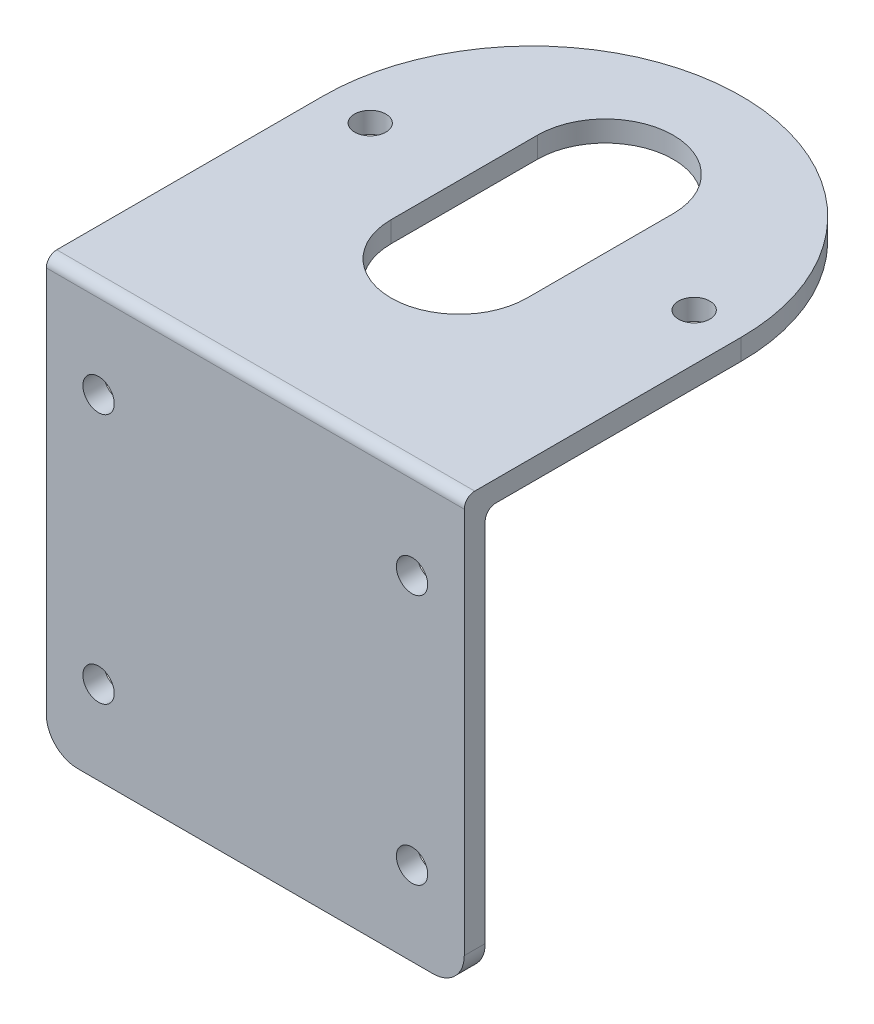
from build123d import *

# Parameters (mm, degrees)
SKETCH_1_W      = 40
SKETCH_1_H      = 39
SKETCH_1_R      = 1.5
SKETCH_1_H_2    = 2
EXTRUDE_2_DEPTH = 2
EXTRUDE_3_DEPTH = 2
FILLET_1_R      = 1
FILLET_2_R      = 3


with BuildPart() as part:
    # 草图1 → 凸台-拉伸2 (new body)
    with BuildSketch(Plane.XY):
        with Locations((0, -1)):
            Rectangle(SKETCH_1_W, SKETCH_1_H)
        with Locations((-15, -12.5)):
            Circle(SKETCH_1_R, mode=Mode.SUBTRACT)
        with Locations((15, -12.5)):
            Circle(SKETCH_1_R, mode=Mode.SUBTRACT)
        with Locations((-15, 11.5)):
            Circle(SKETCH_1_R, mode=Mode.SUBTRACT)
        with Locations((15, 11.5)):
            Circle(SKETCH_1_R, mode=Mode.SUBTRACT)
        with Locations((0, 19.5)):
            Rectangle(SKETCH_1_W, SKETCH_1_H_2)
    extrude(amount=EXTRUDE_2_DEPTH)

    # 草图2 → 凸台-拉伸3 (add)
    with BuildSketch(Plane(origin=(0, 18.5, 0), x_dir=(1, 0, 0), z_dir=(0, 1, 0))):
        with BuildLine():
            ThreePointArc((20, 24.5), (0, 44.5), (-20, 24.5))
            Line((-20, 24.5), (-17, 24.5))
            ThreePointArc((-17, 24.5), (-15.5, 26), (-14, 24.5))
            Line((-14, 24.5), (-6.5, 24.5))
            Line((-6.5, 24.5), (-6.5, 31.5))
            ThreePointArc((-6.5, 31.5), (0, 38), (6.5, 31.5))
            Line((6.5, 31.5), (6.5, 24.5))
            Line((6.5, 24.5), (13.998241038, 24.5))
            ThreePointArc((13.998241038, 24.5), (15.5, 26.001758962), (17.001758962, 24.5))
            Line((17.001758962, 24.5), (20, 24.5))
        make_face()
        with BuildLine():
            Line((-17, 24.5), (-20, 24.5))
            ThreePointArc((-20, 24.5), (0, 4.5), (20, 24.5))
            Line((20, 24.5), (17.001758962, 24.5))
            ThreePointArc((17.001758962, 24.5), (15.5, 22.998241038), (13.998241038, 24.5))
            Line((13.998241038, 24.5), (6.5, 24.5))
            Line((6.5, 24.5), (6.5, 17.5))
            ThreePointArc((6.5, 17.5), (0, 11), (-6.5, 17.5))
            Line((-6.5, 17.5), (-6.5, 24.5))
            Line((-6.5, 24.5), (-14, 24.5))
            ThreePointArc((-14, 24.5), (-15.5, 23), (-17, 24.5))
        make_face()
        with BuildLine():
            Line((-20, 24.5), (-20, -2))
            Line((-20, -2), (20, -2))
            Line((20, -2), (20, 24.5))
            ThreePointArc((20, 24.5), (0, 4.5), (-20, 24.5))
        make_face()
    extrude(amount=EXTRUDE_3_DEPTH)

    # 圆角1
    fillet_1_edges = [part.edges().sort_by_distance(p)[0] for p in [
        (0, 18.5, 0),
        (0, 20.5, 2),
    ]]
    fillet(fillet_1_edges, radius=FILLET_1_R)

    # 圆角2
    fillet_2_edges = [part.edges().sort_by_distance(p)[0] for p in [
        (20, -20.5, 1),
        (-20, -20.5, 1),
    ]]
    fillet(fillet_2_edges, radius=FILLET_2_R)


solid = part.part
